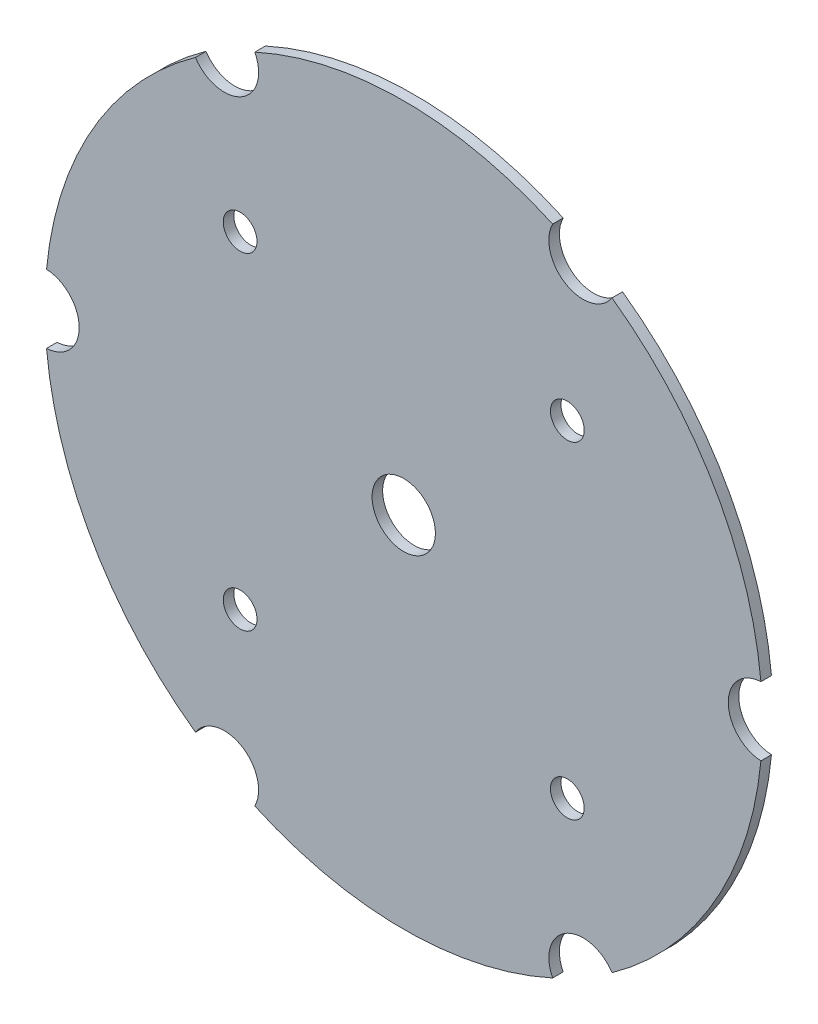
from build123d import *

# Parameters (mm, degrees)
ESQUISSE1_R        = 1.6
ESQUISSE1_R_2      = 3
BOSS_EXTRU_1_DEPTH = 1


with BuildPart() as part:
    # Esquisse1 → Boss.-Extru.1 (new body)
    with BuildSketch(Plane.XY):
        with BuildLine():
            ThreePointArc((33.844669118, -3.246285927), (30.75, 0), (33.844669118, 3.246285927))
            ThreePointArc((33.844669118, 3.246285927), (29.444863729, 17), (19.733700639, 27.687200275))
            ThreePointArc((19.733700639, 27.687200275), (15.375, 26.630281166), (14.110968478, 30.933486202))
            ThreePointArc((14.110968478, 30.933486202), (0, 34), (-14.110968478, 30.933486202))
            ThreePointArc((-14.110968478, 30.933486202), (-13.841531032, 30.210744775), (-13.75, 29.444863729))
            ThreePointArc((-13.75, 29.444863729), (-16.084037959, 26.326608842), (-19.733700639, 27.687200275))
            ThreePointArc((-19.733700639, 27.687200275), (-29.444863729, 17), (-33.844669118, 3.246285927))
            ThreePointArc((-33.844669118, 3.246285927), (-31.64762616, 2.242506927), (-30.75, 0))
            ThreePointArc((-30.75, 0), (-31.64762616, -2.242506927), (-33.844669118, -3.246285927))
            ThreePointArc((-33.844669118, -3.246285927), (-29.444863729, -17), (-19.733700639, -27.687200275))
            ThreePointArc((-19.733700639, -27.687200275), (-16.084037959, -26.326608842), (-13.75, -29.444863729))
            ThreePointArc((-13.75, -29.444863729), (-13.841531032, -30.210744775), (-14.110968478, -30.933486202))
            ThreePointArc((-14.110968478, -30.933486202), (0, -34), (14.110968478, -30.933486202))
            ThreePointArc((14.110968478, -30.933486202), (15.375, -26.630281166), (19.733700639, -27.687200275))
            ThreePointArc((19.733700639, -27.687200275), (29.444863729, -17), (33.844669118, -3.246285927))
        make_face()
        with Locations((-15.5, -15.5)):
            Circle(ESQUISSE1_R, mode=Mode.SUBTRACT)
        with Locations((15.5, -15.5)):
            Circle(ESQUISSE1_R, mode=Mode.SUBTRACT)
        with Locations((-15.5, 15.5)):
            Circle(ESQUISSE1_R, mode=Mode.SUBTRACT)
        Circle(ESQUISSE1_R_2, mode=Mode.SUBTRACT)
        with Locations((15.5, 15.5)):
            Circle(ESQUISSE1_R, mode=Mode.SUBTRACT)
    extrude(amount=BOSS_EXTRU_1_DEPTH)


solid = part.part
